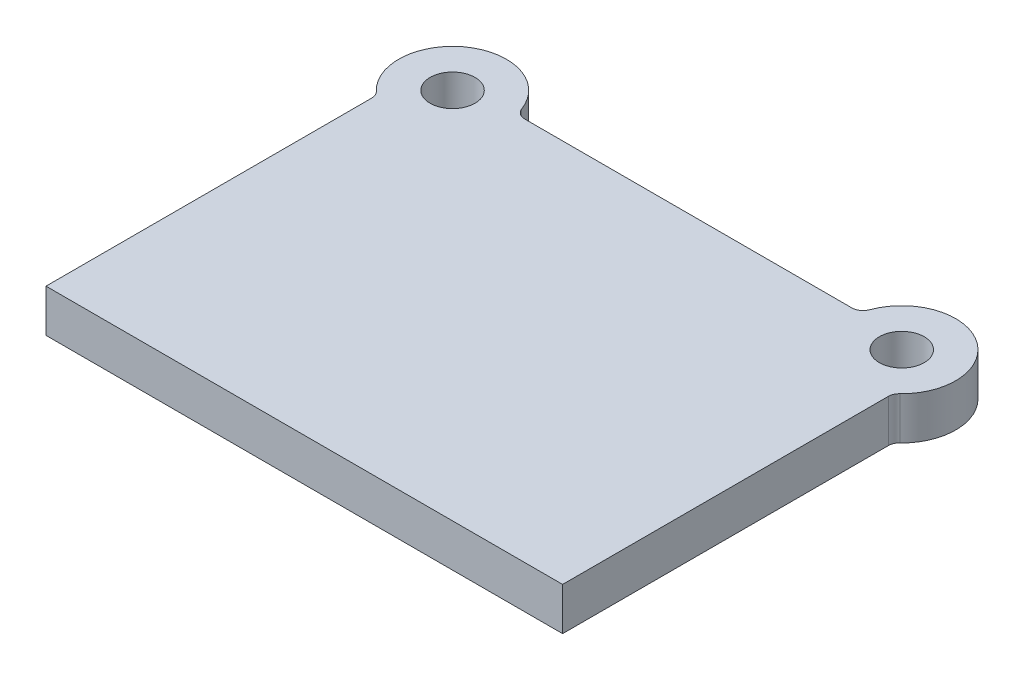
from build123d import *

# Parameters (mm, degrees)
SKETCH1_R           = 20
BOSS_EXTRUDE1_DEPTH = 38
FILLET1_R           = 10


with BuildPart() as part:
    # Sketch1 → Boss-Extrude1 (new body)
    with BuildSketch(Plane(origin=(0, 0, 0), x_dir=(1, 0, 0), z_dir=(0, 1, 0))):
        with BuildLine():
            Line((230, 0), (-230, 0))
            Line((-230, 0), (-230, 294.53001201))
            ThreePointArc((-230, 294.53001201), (-225.20214801, 372.851581802), (-153.053221623, 342))
            Line((-153.053221623, 342), (153.053221623, 342))
            ThreePointArc((153.053221623, 342), (225.20214801, 372.851581802), (230, 294.53001201))
            Line((230, 294.53001201), (230, 0))
        make_face()
        with Locations((-200, 332)):
            Circle(SKETCH1_R, mode=Mode.SUBTRACT)
        with Locations((200, 332)):
            Circle(SKETCH1_R, mode=Mode.SUBTRACT)
    extrude(amount=BOSS_EXTRUDE1_DEPTH)

    # Fillet1
    fillet1_edges = [part.edges().sort_by_distance(p)[0] for p in [
        (-230, 19, -294.53001201),
        (-153.053221623, 19, -342),
        (153.053221623, 19, -342),
        (230, 19, -294.53001201),
    ]]
    fillet(fillet1_edges, radius=FILLET1_R)


solid = part.part
